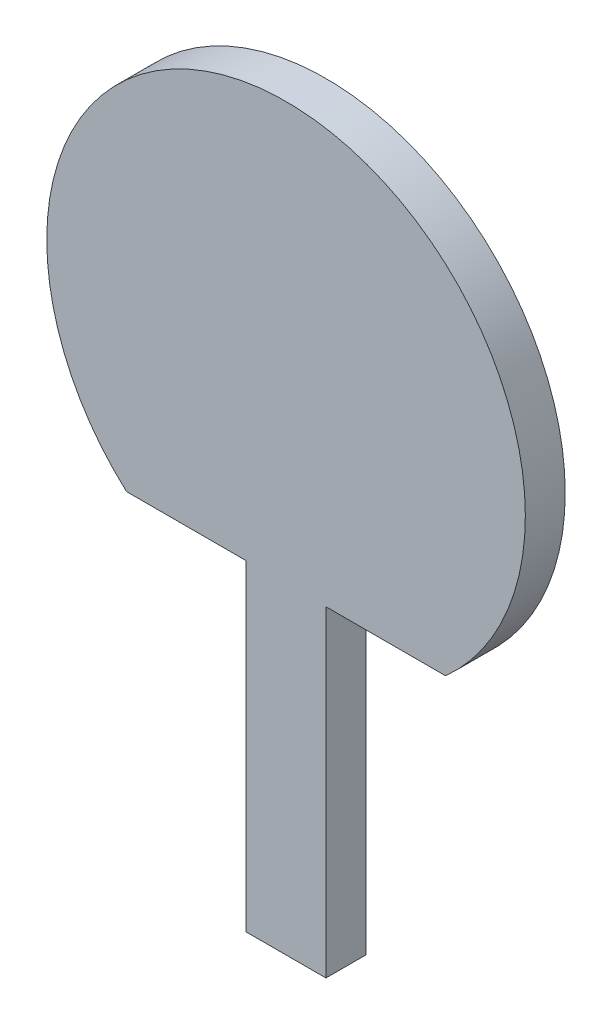
from build123d import *

# Parameters (mm, degrees)
BOSS_EXTRUDE1_DEPTH = 10


with BuildPart() as part:
    # Sketch1 → Boss-Extrude1 (new body)
    with BuildSketch(Plane.XY):
        with BuildLine():
            Line((-40, -44.72135955), (-10, -44.72135955))
            Line((-10, -44.72135955), (-10, -125.340230383))
            Line((-10, -125.340230383), (10, -125.340230383))
            Line((10, -125.340230383), (10, -44.72135955))
            Line((10, -44.72135955), (40, -44.72135955))
            ThreePointArc((40, -44.72135955), (0, 60), (-40, -44.72135955))
        make_face()
    extrude(amount=BOSS_EXTRUDE1_DEPTH)


solid = part.part
